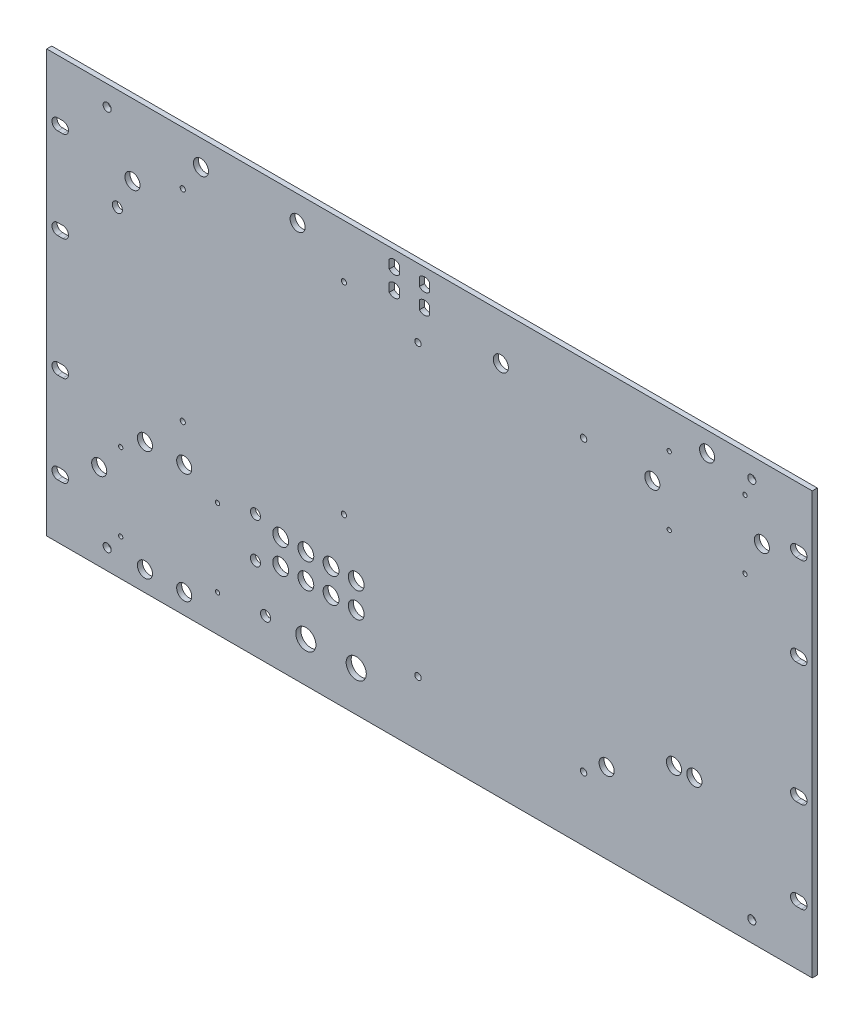
from build123d import *

# Parameters (mm, degrees)
SKETCH1_W              = 482.6
SKETCH1_H              = 265.938
BOSS_EXTRUDE1_DEPTH    = 3.175
CUT_EXTRUDE1_DEPTH     = 4.175
CUT_EXTRUDE2_DEPTH     = 4.175
SKETCH4_R              = 4.7625
CUT_EXTRUDE3_DEPTH     = 4.175
SKETCH5_R              = 4.7625
CUT_EXTRUDE4_DEPTH     = 4.175
F_4_CLEARANCE_HOLE1_D  = 3.2639
SKETCH8_R              = 5
SKETCH8_R_2            = 3.175
SKETCH8_R_3            = 6.35
CUT_EXTRUDE5_DEPTH     = 4.175
SKETCH9_R              = 4.7625
CUT_EXTRUDE6_DEPTH     = 4.175
SKETCH10_R             = 3.175
SKETCH10_R_2           = 4.7625
CUT_EXTRUDE7_DEPTH     = 4.175
F_6_32_TAPPED_HOLE_D   = 2.7051
F_10_32_TAPPED_HOLE1_D = 4.0386
SKETCH15_R             = 4.7625
CUT_EXTRUDE8_DEPTH     = 4.175
SKETCH16_R             = 4.7625
CUT_EXTRUDE9_DEPTH     = 4.175
F_10_CLEARANCE_HOLE1_D = 5.1054


with BuildPart() as part:
    # Sketch1 → Boss-Extrude1 (new body)
    with BuildSketch(Plane.XY):
        Rectangle(SKETCH1_W, SKETCH1_H)
    extrude(amount=BOSS_EXTRUDE1_DEPTH)

    # Sketch2 → Cut-Extrude1 (cut, through all)
    with BuildSketch(Plane.XY.offset(3.175)):
        with BuildLine():
            Line((-234.442, 98.806), (-231.14, 98.806))
            ThreePointArc((-231.14, 98.806), (-227.584, 95.25), (-231.14, 91.694))
            Line((-231.14, 91.694), (-234.442, 91.694))
            ThreePointArc((-234.442, 91.694), (-237.998, 95.25), (-234.442, 98.806))
        make_face()
        with BuildLine():
            Line((-234.442, 41.656), (-231.14, 41.656))
            ThreePointArc((-231.14, 41.656), (-227.584, 38.1), (-231.14, 34.544))
            Line((-231.14, 34.544), (-234.442, 34.544))
            ThreePointArc((-234.442, 34.544), (-237.998, 38.1), (-234.442, 41.656))
        make_face()
        with BuildLine():
            Line((-234.442, -34.544), (-231.14, -34.544))
            ThreePointArc((-231.14, -34.544), (-227.584, -38.1), (-231.14, -41.656))
            Line((-231.14, -41.656), (-234.442, -41.656))
            ThreePointArc((-234.442, -41.656), (-237.998, -38.1), (-234.442, -34.544))
        make_face()
        with BuildLine():
            Line((-234.442, -91.694), (-231.14, -91.694))
            ThreePointArc((-231.14, -91.694), (-227.584, -95.25), (-231.14, -98.806))
            Line((-231.14, -98.806), (-234.442, -98.806))
            ThreePointArc((-234.442, -98.806), (-237.998, -95.25), (-234.442, -91.694))
        make_face()
    cut_extrude1 = extrude(amount=-CUT_EXTRUDE1_DEPTH, mode=Mode.SUBTRACT)

    # Mirror1: Cut-Extrude1 across plane
    add(cut_extrude1.mirror(Plane(origin=(0, 0, 0), x_dir=(0, 0, 1), z_dir=(1, 0, 0))), mode=Mode.SUBTRACT)

    # Sketch3 → Cut-Extrude2 (cut, through all)
    with BuildSketch(Plane(origin=(-181.02162033, -243.631772018, 3.175), x_dir=(1, 0, 0), z_dir=(0, 0, 1))):
        with BuildLine():
            Line((181.048825452, 369.772362154), (181.048825452, 364.379181883))
            ThreePointArc((181.048825452, 364.379181883), (177.873825452, 362.910172018), (174.698825452, 364.379181883))
            Line((174.698825452, 364.379181883), (174.698825452, 369.772362154))
            ThreePointArc((174.698825452, 369.772362154), (177.873825452, 371.241372018), (181.048825452, 369.772362154))
        make_face()
        with BuildLine():
            Line((161.998825452, 369.772362154), (161.998825452, 364.379181883))
            ThreePointArc((161.998825452, 364.379181883), (158.823825452, 362.910172018), (155.648825452, 364.379181883))
            Line((155.648825452, 364.379181883), (155.648825452, 369.772362154))
            ThreePointArc((155.648825452, 369.772362154), (158.823825452, 371.241372018), (161.998825452, 369.772362154))
        make_face()
        with BuildLine():
            Line((161.998825452, 357.072362154), (161.998825452, 351.679181883))
            ThreePointArc((161.998825452, 351.679181883), (158.823825452, 350.210172018), (155.648825452, 351.679181883))
            Line((155.648825452, 351.679181883), (155.648825452, 357.072362154))
            ThreePointArc((155.648825452, 357.072362154), (158.823825452, 358.541372018), (161.998825452, 357.072362154))
        make_face()
        with BuildLine():
            Line((174.698825452, 357.072362154), (174.698825452, 351.679181883))
            ThreePointArc((174.698825452, 351.679181883), (177.873825452, 350.210172018), (181.048825452, 351.679181883))
            Line((181.048825452, 351.679181883), (181.048825452, 357.072362154))
            ThreePointArc((181.048825452, 357.072362154), (177.873825452, 358.541372018), (174.698825452, 357.072362154))
        make_face()
    extrude(amount=-CUT_EXTRUDE2_DEPTH, mode=Mode.SUBTRACT)

    # Sketch4 → Cut-Extrude3 (cut, through all)
    with BuildSketch(Plane(origin=(-181.02162033, -243.631772018, 3.175), x_dir=(1, 0, 0), z_dir=(0, 0, 1))):
        with Locations((97.88742033, 360.651377141)):
            Circle(SKETCH4_R)
        with Locations((36.946803704, 360.651377141)):
            Circle(SKETCH4_R)
    extrude(amount=-CUT_EXTRUDE3_DEPTH, mode=Mode.SUBTRACT)

    # Sketch5 → Cut-Extrude4 (cut, through all)
    with BuildSketch(Plane(origin=(-181.02162033, -243.631772018, 3.175), x_dir=(1, 0, 0), z_dir=(0, 0, 1))):
        with Locations((225.993210145, 348.025772018)):
            Circle(SKETCH5_R)
        with Locations((292.693482391, 161.058252354)):
            Circle(SKETCH5_R)
    extrude(amount=-CUT_EXTRUDE4_DEPTH, mode=Mode.SUBTRACT)

    # #4 Clearance Hole1 (through all)
    with Locations(Plane(origin=(-181.02162033, -243.631772018, 0), x_dir=(-1, 0, 0), z_dir=(0, 0, -1))):
        with Locations((-127.09742033, 343.110872018), (-25.49742033, 343.110872018), (-25.49742033, 216.110872018), (-127.09742033, 216.110872018)):
            Hole(F_4_CLEARANCE_HOLE1_D / 2)

    # Sketch8 → Cut-Extrude5 (cut, through all)
    with BuildSketch(Plane(origin=(-181.02162033, -243.631772018, 3.175), x_dir=(1, 0, 0), z_dir=(0, 0, 1))):
        with Locations((87.210707903, 183.695733345)):
            Circle(SKETCH8_R)
        with Locations((103.085707903, 183.695733345)):
            Circle(SKETCH8_R)
        with Locations((118.960707903, 183.695733345)):
            Circle(SKETCH8_R)
        with Locations((134.835707903, 183.695733345)):
            Circle(SKETCH8_R)
        with Locations((134.835707903, 167.820733345)):
            Circle(SKETCH8_R)
        with Locations((118.960707903, 167.820733345)):
            Circle(SKETCH8_R)
        with Locations((103.085707903, 167.820733345)):
            Circle(SKETCH8_R)
        with Locations((87.210707903, 167.820733345)):
            Circle(SKETCH8_R)
        with Locations((71.335707903, 188.458233345)):
            Circle(SKETCH8_R_2)
        with Locations((71.335707903, 163.058233345)):
            Circle(SKETCH8_R_2)
        with Locations((103.085707903, 136.070733345)):
            Circle(SKETCH8_R_3)
        with Locations((134.835707903, 136.070733345)):
            Circle(SKETCH8_R_3)
        with Locations((77.685707903, 136.070733345)):
            Circle(SKETCH8_R_2)
    extrude(amount=-CUT_EXTRUDE5_DEPTH, mode=Mode.SUBTRACT)

    # Sketch9 → Cut-Extrude6 (cut, through all)
    with BuildSketch(Plane(origin=(-181.02162033, -243.631772018, 3.175), x_dir=(1, 0, 0), z_dir=(0, 0, 1))):
        with Locations((26.393194264, 192.958772018)):
            Circle(SKETCH9_R)
        with Locations((1.630666307, 192.958772018)):
            Circle(SKETCH9_R)
        with Locations((1.630666307, 123.362772018)):
            Circle(SKETCH9_R)
        with Locations((26.393194264, 123.362772018)):
            Circle(SKETCH9_R)
        with Locations((-27.185282018, 164.860944472)):
            Circle(SKETCH9_R)
    extrude(amount=-CUT_EXTRUDE6_DEPTH, mode=Mode.SUBTRACT)

    # Sketch10 → Cut-Extrude7 (cut, through all)
    with BuildSketch(Plane(origin=(-181.02162033, -243.631772018, 3.175), x_dir=(1, 0, 0), z_dir=(0, 0, 1))):
        with Locations((-15.753984793, 312.422144018)):
            Circle(SKETCH10_R)
        with Locations((-6.228984793, 331.472144018)):
            Circle(SKETCH10_R_2)
    extrude(amount=-CUT_EXTRUDE7_DEPTH, mode=Mode.SUBTRACT)

    # #6-32 Tapped Hole (through all)
    with Locations(Plane(origin=(-181.02162033, -243.631772018, 3.175), x_dir=(1, 0, 0), z_dir=(0, 0, 1))):
        with Locations((-13.634382018, 182.582872018), (47.401817982, 182.582872018), (47.401817982, 133.738672018), (-13.634382018, 133.738672018), (332.15162033, 353.232772018), (379.90362033, 353.232772018), (379.90362033, 310.179772018), (332.153973797, 310.179772018)):
            Hole(F_6_32_TAPPED_HOLE_D / 2)

    # #10-32 Tapped Hole1 (through all)
    with Locations(Plane(origin=(-181.02162033, -243.631772018, 3.175), x_dir=(1, 0, 0), z_dir=(0, 0, 1))):
        with Locations((278.168010145, 333.298282981), (173.774010145, 333.298282981), (173.774010145, 151.027882981), (278.168010145, 151.027882981)):
            Hole(F_10_32_TAPPED_HOLE1_D / 2)

    # Sketch15 → Cut-Extrude8 (cut, through all)
    with BuildSketch(Plane(origin=(-181.02162033, -243.631772018, 3.175), x_dir=(1, 0, 0), z_dir=(0, 0, 1))):
        with Locations((321.48362033, 331.756823693)):
            Circle(SKETCH15_R)
        with Locations((356.032924126, 363.900772018)):
            Circle(SKETCH15_R)
        with Locations((390.57162033, 331.759308089)):
            Circle(SKETCH15_R)
    extrude(amount=-CUT_EXTRUDE8_DEPTH, mode=Mode.SUBTRACT)

    # Sketch16 → Cut-Extrude9 (cut, through all)
    with BuildSketch(Plane(origin=(-181.02162033, -243.631772018, 3.175), x_dir=(1, 0, 0), z_dir=(0, 0, 1))):
        with Locations((335.161382997, 182.894837455)):
            Circle(SKETCH16_R)
        with Locations((348.023271542, 182.894837455)):
            Circle(SKETCH16_R)
    extrude(amount=-CUT_EXTRUDE9_DEPTH, mode=Mode.SUBTRACT)

    # #10 Clearance Hole1 (through all)
    with Locations(Plane(origin=(-181.02162033, -243.631772018, 3.175), x_dir=(1, 0, 0), z_dir=(0, 0, 1))):
        with Locations((-22.17837967, 363.900772018), (384.22162033, 363.900772018), (384.22162033, 123.362772018), (-22.17837967, 123.362772018)):
            Hole(F_10_CLEARANCE_HOLE1_D / 2)


solid = part.part
